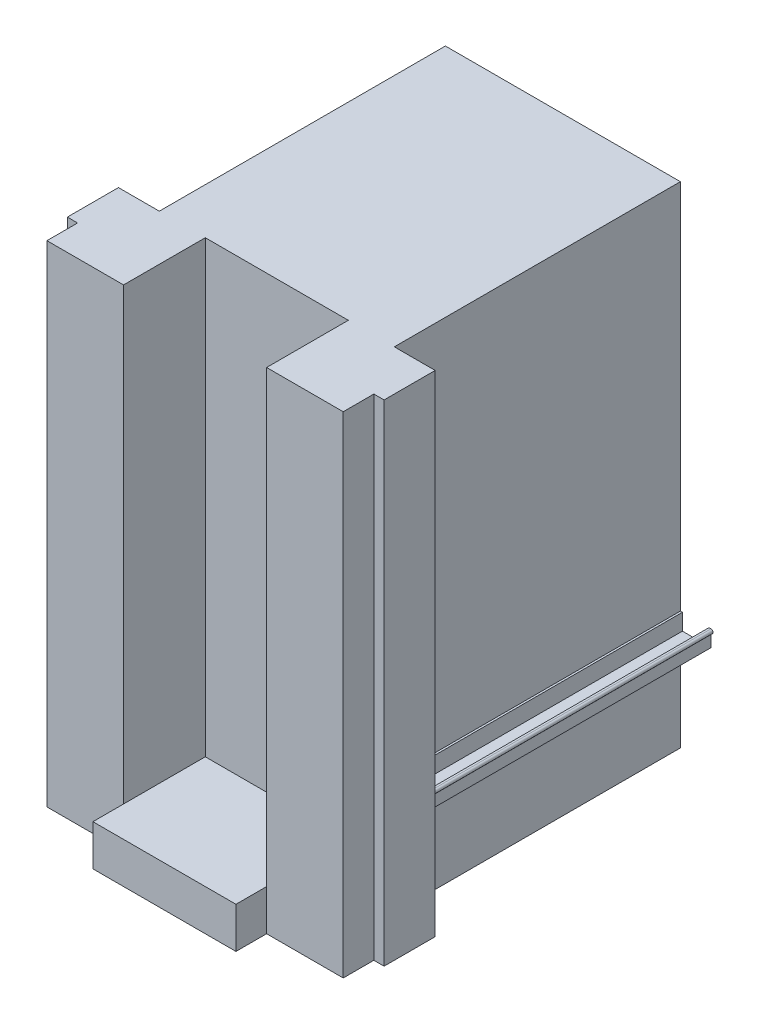
from build123d import *

# Parameters (mm, degrees)
EXTRUDE_1_DEPTH      = 1400
SKETCH_3_W           = 1550
SKETCH_3_H           = 2400
EXTRUDE_2_DEPTH      = 400
SKETCH_4_W           = 50
SKETCH_4_H           = 150
SKETCH_4_W_2         = 700
SKETCH_4_H_2         = 400
CUT_EXTRUDE_1_DEPTH  = 2401
SKETCH_5_W           = 700
SKETCH_5_H           = 200
EXTRUDE_3_DEPTH      = 150
EXTRUDE_3_DEPTH_BACK = 1800


with BuildPart() as part:
    # 草圖1 → 填料-伸長1 (new body)
    with BuildSketch(Plane.XY):
        with BuildLine():
            ThreePointArc((-725, 329.458185741), (-735, 319.458185741), (-725, 309.458185741))
            Line((-725, 309.458185741), (-725, 249.458185741))
            Line((-725, 249.458185741), (-692.026095563, 239.458185741))
            Line((-692.026095563, 239.458185741), (-575, 239.458185741))
            Line((-575, 239.458185741), (-575, -250.541814259))
            Line((-575, -250.541814259), (0, -250.541814259))
            Line((0, -250.541814259), (0, 2149.458185741))
            Line((0, 2149.458185741), (-575, 2149.458185741))
            Line((-575, 2149.458185741), (-575, 329.458185741))
            Line((-575, 329.458185741), (-584.95081424, 329.458185741))
            Line((-584.95081424, 329.458185741), (-584.95081424, 249.408999982))
            Line((-584.95081424, 249.408999982), (-715.04918576, 249.408999982))
            Line((-715.04918576, 249.408999982), (-715.04918576, 329.458185741))
            Line((-715.04918576, 329.458185741), (-725, 329.458185741))
        make_face()
        with BuildLine():
            Line((0, 2149.458185741), (0, -250.541814259))
            Line((0, -250.541814259), (575, -250.541814259))
            Line((575, -250.541814259), (575, 239.458185741))
            Line((575, 239.458185741), (692.026095563, 239.458185741))
            Line((692.026095563, 239.458185741), (725, 249.458185741))
            Line((725, 249.458185741), (725, 309.458185741))
            ThreePointArc((725, 309.458185741), (735, 319.458185741), (725, 329.458185741))
            Line((725, 329.458185741), (715.04918576, 329.458185741))
            Line((715.04918576, 329.458185741), (715.04918576, 249.408999982))
            Line((715.04918576, 249.408999982), (584.95081424, 249.408999982))
            Line((584.95081424, 249.408999982), (584.95081424, 329.458185741))
            Line((584.95081424, 329.458185741), (575, 329.458185741))
            Line((575, 329.458185741), (575, 2149.458185741))
            Line((575, 2149.458185741), (0, 2149.458185741))
        make_face()
    extrude(amount=EXTRUDE_1_DEPTH)

    # 草圖3 → 填料-伸長2 (add)
    with BuildSketch(Plane.XY.offset(1400)):
        with Locations((0, 949.458185741)):
            Rectangle(SKETCH_3_W, SKETCH_3_H)
    extrude(amount=EXTRUDE_2_DEPTH)

    # 草圖4 → 除料-伸長1 (cut, through all)
    with BuildSketch(Plane(origin=(0, 2149.458185741, 0), x_dir=(1, 0, 0), z_dir=(0, 1, 0))):
        with Locations((-750, -1725)):
            Rectangle(SKETCH_4_W, SKETCH_4_H)
        with Locations((750, -1725)):
            Rectangle(SKETCH_4_W, SKETCH_4_H)
        with Locations((0, -1600)):
            Rectangle(SKETCH_4_W_2, SKETCH_4_H_2)
    extrude(amount=-CUT_EXTRUDE_1_DEPTH, mode=Mode.SUBTRACT)

    # 草圖5 → 填料-伸長3 (add, two sides)
    with BuildSketch(Plane.XY.offset(1800)) as extrude_3_sk:
        with Locations((0, -150.541814259)):
            Rectangle(SKETCH_5_W, SKETCH_5_H)
    extrude(amount=EXTRUDE_3_DEPTH)
    extrude(extrude_3_sk.sketch, amount=-EXTRUDE_3_DEPTH_BACK)


solid = part.part
